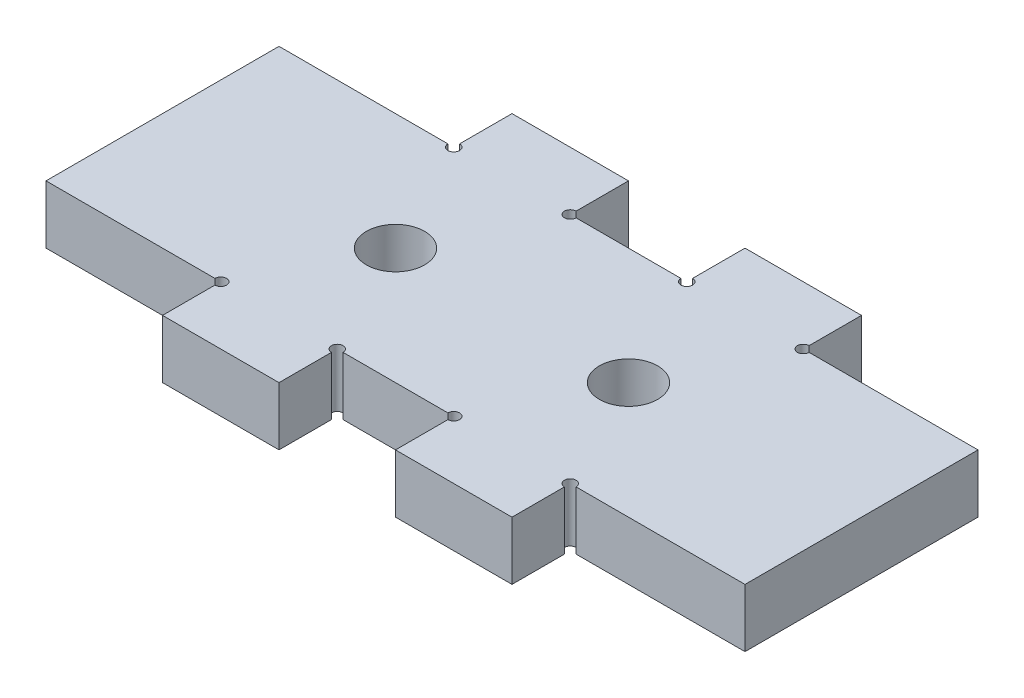
from build123d import *

# Parameters (mm, degrees)
BOSS_EXTRUDE1_DEPTH = 6.35
CUT_EXTRUDE1_REACH  = 45.068
SKETCH2_R           = 3.175
CUT_EXTRUDE2_START  = -6.35
SKETCH4_R           = 0.635
CUT_EXTRUDE2_DEPTH  = 6.35


with BuildPart() as part:
    # Sketch1 → Boss-Extrude1 (new body)
    with BuildSketch(Plane(origin=(0, 0, 0), x_dir=(1, 0, 0), z_dir=(0, 1, 0))):
        Polygon((-19.05, 12.7), (-19.05, 19.05), (-6.35, 19.05), (-6.35, 12.7), (6.35, 12.7), (6.35, 19.05), (19.05, 19.05), (19.05, 12.7), (38.1, 12.7), (38.1, -12.7), (19.05, -12.7), (19.05, -19.05), (6.35, -19.05), (6.35, -12.7), (-6.35, -12.7), (-6.35, -19.05), (-19.05, -19.05), (-19.05, -12.7), (-38.1, -12.7), (-38.1, 12.7), align=None)
    extrude(amount=BOSS_EXTRUDE1_DEPTH)

    # Sketch2 → Cut-Extrude1 (cut, up to next)
    with BuildSketch(Plane(origin=(0, 6.35, 0), x_dir=(1, 0, 0), z_dir=(0, 1, 0)), mode=Mode.PRIVATE) as cut_extrude1_sk1:
        with Locations(Location((-12.7, 0, 0), (0, 0, 270))):
            Circle(SKETCH2_R)
    cut_extrude1_tool1 = extrude(cut_extrude1_sk1.sketch, amount=-CUT_EXTRUDE1_REACH, mode=Mode.PRIVATE) & part.part
    # Sketch2 → Cut-Extrude1 (cut, up to next)
    with BuildSketch(Plane(origin=(0, 6.35, 0), x_dir=(1, 0, 0), z_dir=(0, 1, 0)), mode=Mode.PRIVATE) as cut_extrude1_sk2:
        with Locations(Location((12.7, 0, 0), (0, 0, 270))):
            Circle(SKETCH2_R)
    cut_extrude1_tool2 = extrude(cut_extrude1_sk2.sketch, amount=-CUT_EXTRUDE1_REACH, mode=Mode.PRIVATE) & part.part
    add(cut_extrude1_tool1.solids().sort_by_distance((-12.7, 6.35, 0))[0], mode=Mode.SUBTRACT)
    add(cut_extrude1_tool2.solids().sort_by_distance((12.7, 6.35, 0))[0], mode=Mode.SUBTRACT)

    # Sketch4 → Cut-Extrude2 (cut)
    with BuildSketch(Plane(origin=(0, 6.35, 0), x_dir=(1, 0, 0), z_dir=(0, 1, 0)).offset(CUT_EXTRUDE2_START)):
        with Locations((-19.05, 12.7)):
            Circle(SKETCH4_R)
    cut_extrude2 = extrude(amount=CUT_EXTRUDE2_DEPTH, mode=Mode.SUBTRACT)

    # Sketch-Pattern1: Cut-Extrude2 at 7 more places
    with Locations((12.7, 0, 0), (25.4, 0, 0), (38.1, 0, 0), (38.1, 0, 25.4), (25.4, 0, 25.4), (12.7, 0, 25.4), (0, 0, 25.4)):
        add(cut_extrude2, mode=Mode.SUBTRACT)


solid = part.part
